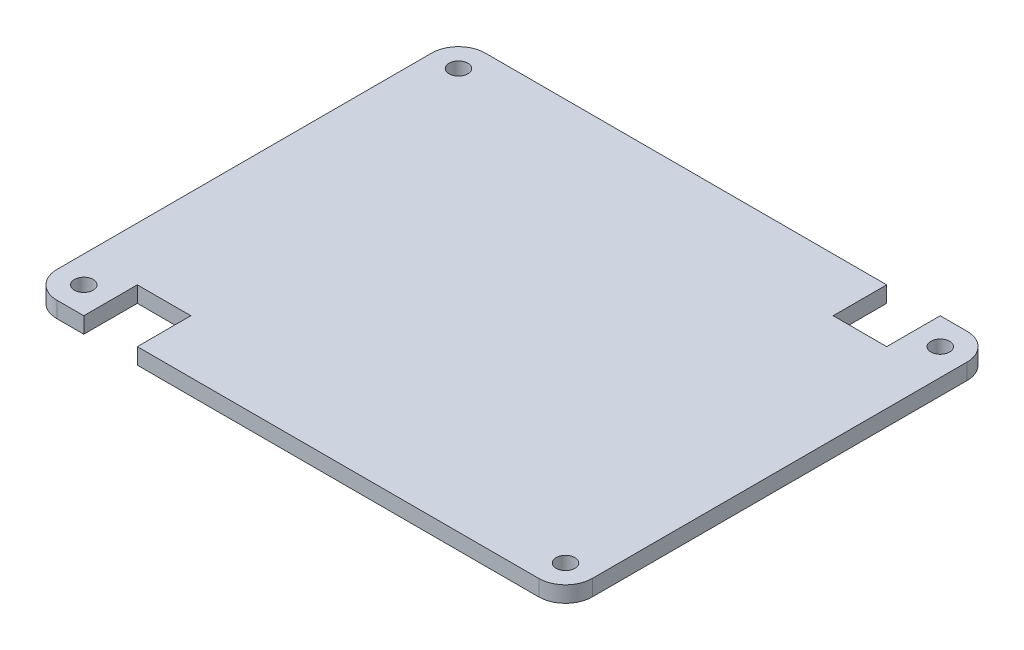
from build123d import *

# Parameters (mm, degrees)
BOSS_EXTRUDE1_DEPTH  = 3
SKETCH3_R            = 1.75
CUT_EXTRUDE2_DEPTH   = 4
LPATTERN1_COUNT      = 2
LPATTERN1_PITCH      = 70
LPATTERN1_COUNT_DIR2 = 2
LPATTERN1_PITCH_DIR2 = 90
SKETCH5_W            = 10
SKETCH5_H            = 10
CUT_EXTRUDE4_DEPTH   = 4


with BuildPart() as part:
    # Sketch1 → Boss-Extrude1 (new body)
    with BuildSketch(Plane(origin=(0, 0, 0), x_dir=(1, 0, 0), z_dir=(0, 1, 0))):
        with BuildLine():
            Line((-45, 40), (45, 40))
            ThreePointArc((45, 40), (48.535533906, 38.535533906), (50, 35))
            Line((50, 35), (50, -35))
            ThreePointArc((50, -35), (48.535533906, -38.535533906), (45, -40))
            Line((45, -40), (-45, -40))
            ThreePointArc((-45, -40), (-48.535533906, -38.535533906), (-50, -35))
            Line((-50, -35), (-50, 35))
            ThreePointArc((-50, 35), (-48.535533906, 38.535533906), (-45, 40))
        make_face()
    extrude(amount=BOSS_EXTRUDE1_DEPTH)

    # Sketch3 → Cut-Extrude2 (cut, through all)
    with BuildSketch(Plane(origin=(0, 3, 0), x_dir=(1, 0, 0), z_dir=(0, 1, 0))):
        with Locations((-45, -35)):
            Circle(SKETCH3_R)
    cut_extrude2 = extrude(amount=-CUT_EXTRUDE2_DEPTH, mode=Mode.SUBTRACT)

    # LPattern1: Cut-Extrude2 2 × 2
    with Locations(*[(j * LPATTERN1_PITCH_DIR2, 0, -i * LPATTERN1_PITCH) for i in range(LPATTERN1_COUNT) for j in range(LPATTERN1_COUNT_DIR2) if (i, j) != (0, 0)]):
        add(cut_extrude2, mode=Mode.SUBTRACT)

    # Sketch5 → Cut-Extrude4 (cut, through all)
    with BuildSketch(Plane(origin=(0, 3, 0), x_dir=(1, 0, 0), z_dir=(0, 1, 0))):
        with Locations((-35, -35)):
            Rectangle(SKETCH5_W, SKETCH5_H)
        with Locations((35, 35)):
            Rectangle(SKETCH5_W, SKETCH5_H)
    extrude(amount=-CUT_EXTRUDE4_DEPTH, mode=Mode.SUBTRACT)


solid = part.part
